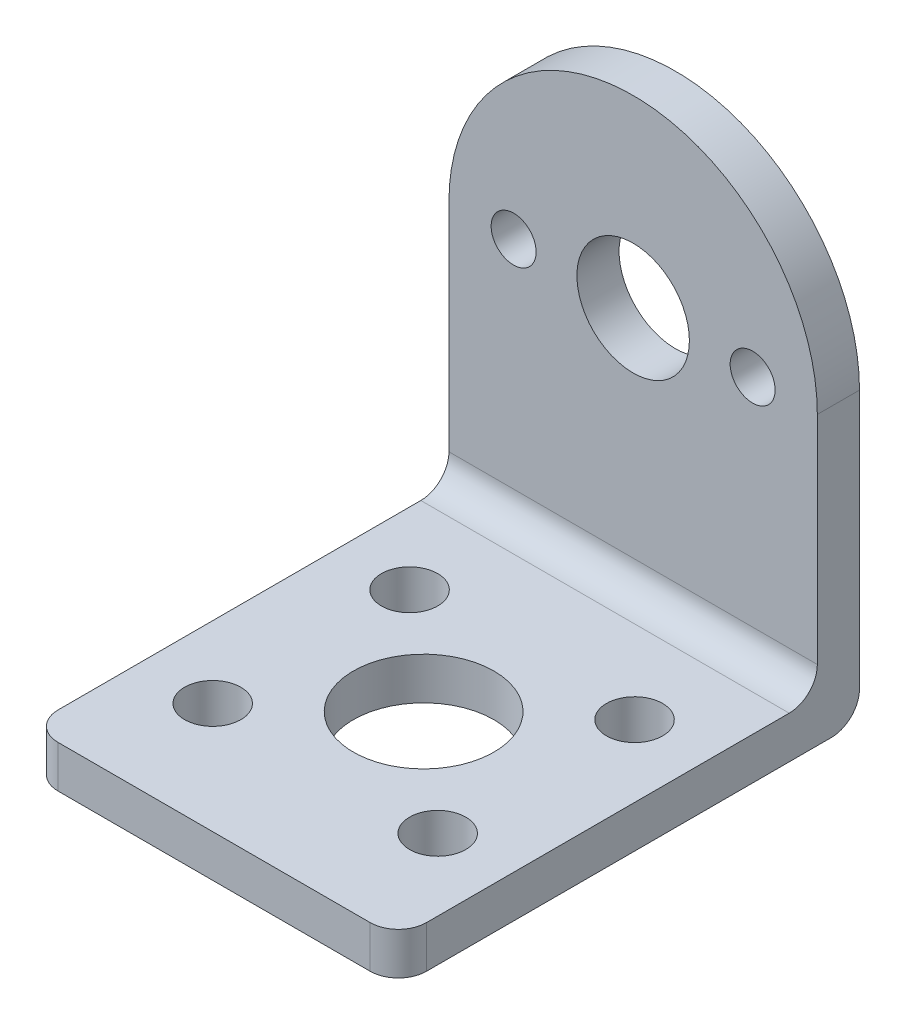
from build123d import *

# Parameters (mm, degrees)
SKETCH1_R           = 4
SKETCH1_R_2         = 1.6
BOSS_EXTRUDE1_DEPTH = 3
SKETCH2_W           = 26.2
SKETCH2_H           = 29.8
SKETCH2_R           = 2
SKETCH2_R_2         = 5
BOSS_EXTRUDE2_DEPTH = 3
FILLET1_R           = 2


with BuildPart() as part:
    # Sketch1 → Boss-Extrude1 (new body)
    with BuildSketch(Plane.XY):
        with BuildLine():
            Line((-13.1, 20.4), (-13.1, 0))
            Line((-13.1, 0), (13.1, 0))
            Line((13.1, 0), (13.1, 20.4))
            ThreePointArc((13.1, 20.4), (0, 33.5), (-13.1, 20.4))
        make_face()
        with Locations((0, 20.4)):
            Circle(SKETCH1_R, mode=Mode.SUBTRACT)
        with Locations((-8.5, 20.4)):
            Circle(SKETCH1_R_2, mode=Mode.SUBTRACT)
        with Locations((8.5, 20.4)):
            Circle(SKETCH1_R_2, mode=Mode.SUBTRACT)
    extrude(amount=BOSS_EXTRUDE1_DEPTH)

    # Sketch2 → Boss-Extrude2 (add)
    with BuildSketch(Plane.XZ):
        with Locations((0, 17.9)):
            Rectangle(SKETCH2_W, SKETCH2_H)
        with Locations((8, 24.9)):
            Circle(SKETCH2_R, mode=Mode.SUBTRACT)
        with Locations((8, 10.9)):
            Circle(SKETCH2_R, mode=Mode.SUBTRACT)
        with Locations((-8, 10.9)):
            Circle(SKETCH2_R, mode=Mode.SUBTRACT)
        with Locations((-8, 24.9)):
            Circle(SKETCH2_R, mode=Mode.SUBTRACT)
        with Locations((0, 17.9)):
            Circle(SKETCH2_R_2, mode=Mode.SUBTRACT)
    extrude(amount=-BOSS_EXTRUDE2_DEPTH)

    # Fillet1
    fillet1_edges = [part.edges().sort_by_distance(p)[0] for p in [
        (13.1, 1.5, 32.8),
        (0, 3, 3),
        (-13.1, 1.5, 32.8),
        (0, 0, 0),
    ]]
    fillet(fillet1_edges, radius=FILLET1_R)


solid = part.part
